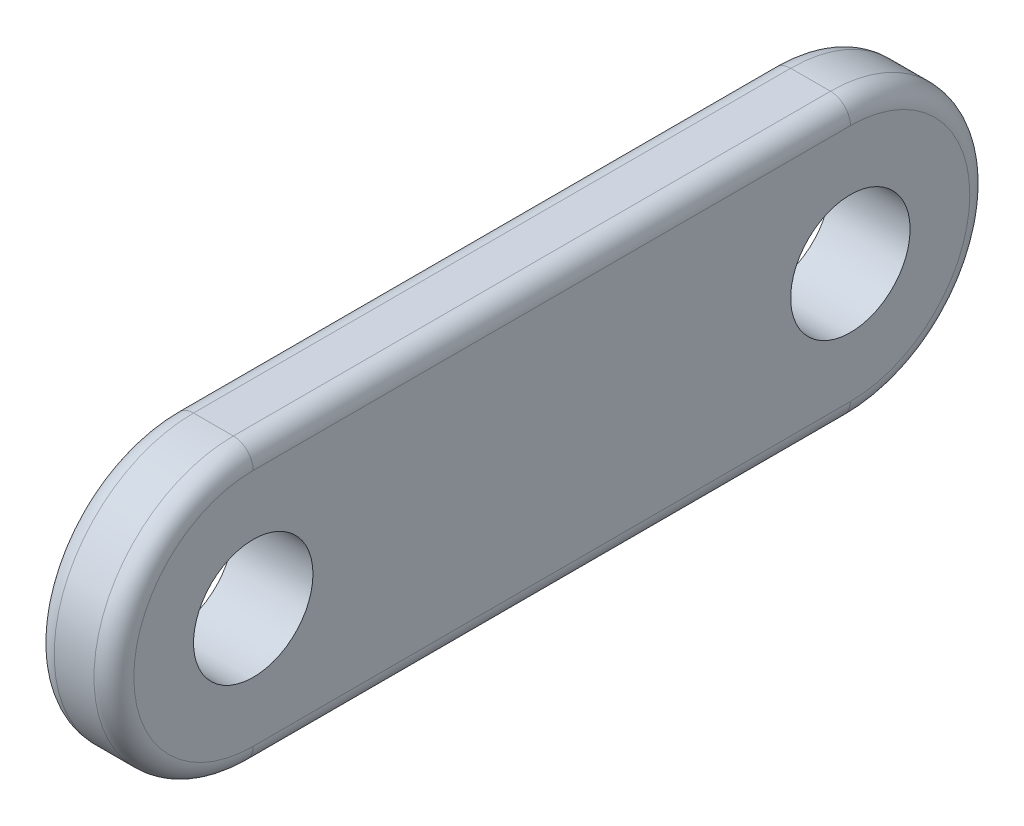
from build123d import *

# Parameters (mm, degrees)
SKETCH_1_R      = 3
EXTRUDE_1_DEPTH = 4
FILLET_1_R      = 1


with BuildPart() as part:
    # 草图1 → 凸台-拉伸1 (new body)
    with BuildSketch(Plane(origin=(0, 0, 0), x_dir=(0, 0, -1), z_dir=(1, 0, 0))):
        with BuildLine():
            Line((-15, 7), (15, 7))
            ThreePointArc((15, 7), (22, 0), (15, -7))
            Line((15, -7), (-15, -7))
            ThreePointArc((-15, -7), (-22, 0), (-15, 7))
        make_face()
        with Locations((-15, 0)):
            Circle(SKETCH_1_R, mode=Mode.SUBTRACT)
        with Locations((15, 0)):
            Circle(SKETCH_1_R, mode=Mode.SUBTRACT)
    extrude(amount=EXTRUDE_1_DEPTH)

    # 圆角1
    fillet_1_edges = [part.edges().sort_by_distance(p)[0] for p in [
        (4, 0, -22),
        (4, 7, 0),
        (4, 0, 22),
        (0, 7, 0),
        (0, 0, -22),
        (0, -7, 0),
        (0, 0, 22),
        (4, -7, 0),
    ]]
    fillet(fillet_1_edges, radius=FILLET_1_R)


solid = part.part
